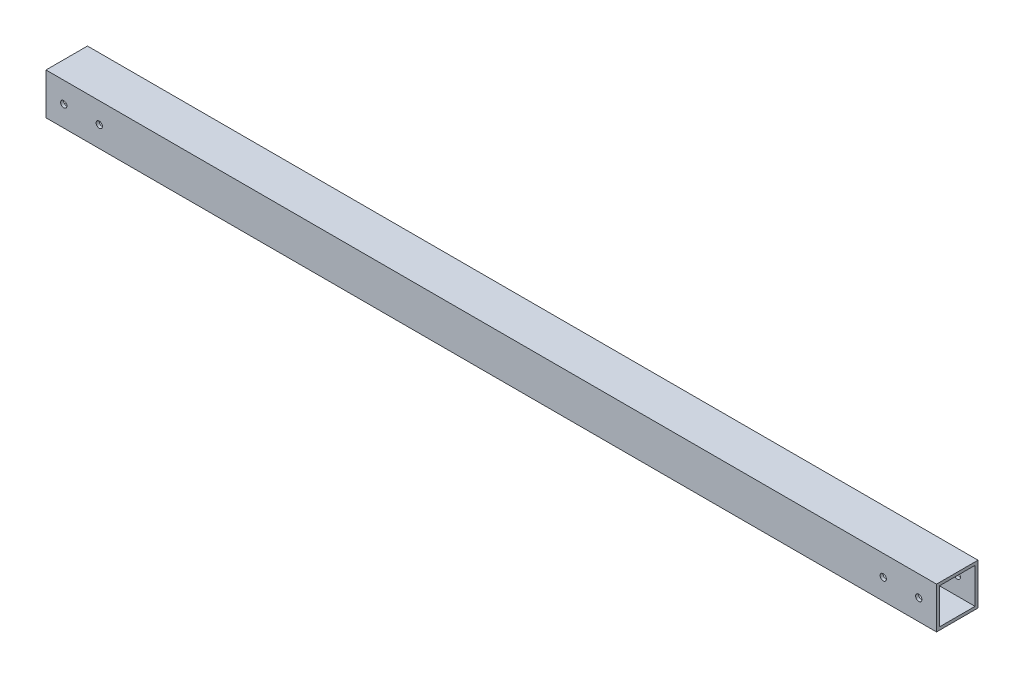
from build123d import *

# Parameters (mm, degrees)
SKETCH1_W               = 44.45
SKETCH1_H               = 44.45
SKETCH1_W_2             = 38.1
SKETCH1_H_2             = 38.1
BOSS_EXTRUDE1_DEPTH     = 954.786
F_1_4_CLEARANCE_HOLE1_D = 6.7564


with BuildPart() as part:
    # Sketch1 → Boss-Extrude1 (new body)
    with BuildSketch(Plane(origin=(0, 0, 0), x_dir=(0, 0, -1), z_dir=(1, 0, 0))):
        with Locations((22.225, 22.225)):
            Rectangle(SKETCH1_W, SKETCH1_H)
        with Locations((22.225, 22.225)):
            Rectangle(SKETCH1_W_2, SKETCH1_H_2, mode=Mode.SUBTRACT)
    extrude(amount=BOSS_EXTRUDE1_DEPTH)

    # 1/4 Clearance Hole1 (through all)
    with Locations(Plane.XY):
        with Locations((19.05, 22.225), (57.15, 22.225), (935.736, 22.225), (897.636, 22.225)):
            Hole(F_1_4_CLEARANCE_HOLE1_D / 2)


solid = part.part
